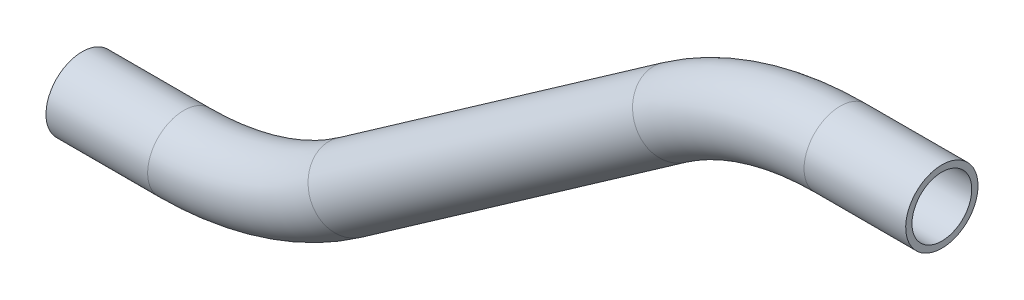
from build123d import *

# Parameters (mm, degrees)
SKETCH5_R   = 9.525
SKETCH5_R_2 = 7.874


with BuildPart() as part:
    # Sweep1: sweep along a path in Sketch4
    with BuildLine(Plane.XY) as sweep1_path:
        Line((121.865926636, 47.432526586), (95.091694349, 47.432526586))
        ThreePointArc((95.091694349, 47.432526586), (72.177912426, 43.905758233), (51.385169899, 33.651912361))
        Line((51.385169899, 33.651912361), (-34.092088176, -26.199908089))
        ThreePointArc((-34.092088176, -26.199908089), (-54.884830704, -36.453753961), (-77.798612626, -39.980522314))
        Line((-77.798612626, -39.980522314), (-104.572844914, -39.980522314))
    # Sketch5 → Sweep1 (sweep)
    with BuildSketch(Plane(origin=(121.865926636, 47.432526586, 0), x_dir=(0, 0, 1), z_dir=(-1, 0, 0))):
        Circle(SKETCH5_R)
        Circle(SKETCH5_R_2, mode=Mode.SUBTRACT)
    sweep(path=sweep1_path.line)


solid = part.part
